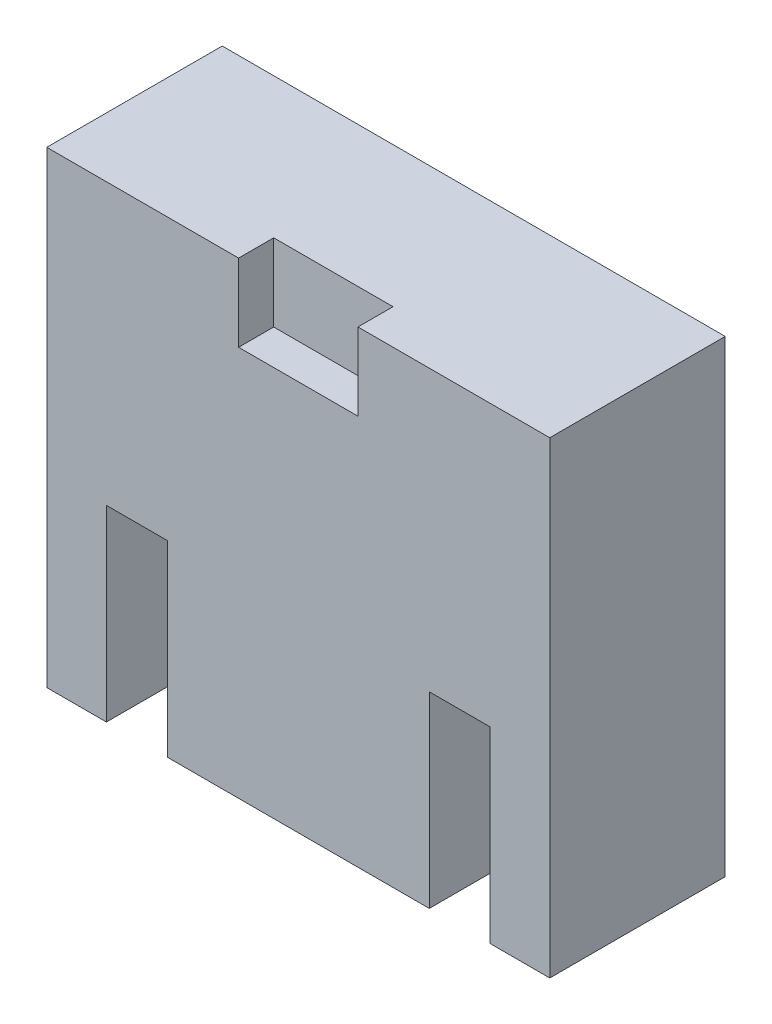
from build123d import *

# Parameters (mm, degrees)
SKETCH1_W           = 43
SKETCH1_H           = 40
BOSS_EXTRUDE1_DEPTH = 15
SKETCH3_W           = 10.2
SKETCH3_H           = 6.605333129
CUT_EXTRUDE1_DEPTH  = 3
SKETCH3_4_W         = 5.2
SKETCH3_4_H         = 16.040940276
CUT_EXTRUDE2_DEPTH  = 10


with BuildPart() as part:
    # Sketch1 → Boss-Extrude1 (new body)
    with BuildSketch(Plane.XY):
        with Locations((1.748803828, 1.277511962)):
            Rectangle(SKETCH1_W, SKETCH1_H)
    extrude(amount=BOSS_EXTRUDE1_DEPTH)

    # Sketch3 → Cut-Extrude1 (cut)
    with BuildSketch(Plane.XY.offset(15)):
        with Locations((1.748803828, 17.974845398)):
            Rectangle(SKETCH3_W, SKETCH3_H)
    extrude(amount=-CUT_EXTRUDE1_DEPTH, mode=Mode.SUBTRACT)

    # Sketch3_4 → Cut-Extrude2 (cut)
    with BuildSketch(Plane.XY.offset(15)):
        with Locations((-12.051196172, -10.7020179)):
            Rectangle(SKETCH3_4_W, SKETCH3_4_H)
        with Locations((15.548803828, -10.7020179)):
            Rectangle(SKETCH3_4_W, SKETCH3_4_H)
    extrude(amount=-CUT_EXTRUDE2_DEPTH, mode=Mode.SUBTRACT)


solid = part.part
